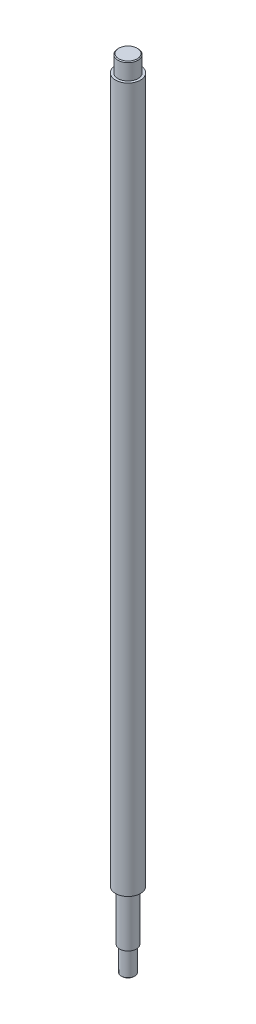
from build123d import *

# Parameters (mm, degrees)
SKETCH4_R           = 7.5
BOSS_EXTRUDE1_DEPTH = 421
SKETCH5_R           = 6
BOSS_EXTRUDE2_DEPTH = 10
CHAMFER1_SIZE       = 0.5
SKETCH6_R           = 5
BOSS_EXTRUDE3_DEPTH = 30
SKETCH7_R           = 4
BOSS_EXTRUDE4_DEPTH = 15
CHAMFER2_SIZE       = 0.5


with BuildPart() as part:
    # Sketch4 → Boss-Extrude1 (new body)
    with BuildSketch(Plane(origin=(0, 0, 0), x_dir=(1, 0, 0), z_dir=(0, 1, 0))):
        Circle(SKETCH4_R)
    extrude(amount=BOSS_EXTRUDE1_DEPTH)

    # Sketch5 → Boss-Extrude2 (add)
    with BuildSketch(Plane(origin=(0, 421, 0), x_dir=(1, 0, 0), z_dir=(0, 1, 0))):
        Circle(SKETCH5_R)
    extrude(amount=BOSS_EXTRUDE2_DEPTH)

    # Chamfer1
    chamfer1_edges = [part.edges().sort_by_distance(p)[0] for p in [
        (-6, 431, 0),
    ]]
    chamfer(chamfer1_edges, length=CHAMFER1_SIZE)

    # Sketch6 → Boss-Extrude3 (add)
    with BuildSketch(Plane.XZ):
        Circle(SKETCH6_R)
    extrude(amount=BOSS_EXTRUDE3_DEPTH)

    # Sketch7 → Boss-Extrude4 (add)
    with BuildSketch(Plane.XZ.offset(30)):
        Circle(SKETCH7_R)
    extrude(amount=BOSS_EXTRUDE4_DEPTH)

    # Chamfer2
    chamfer2_edges = [part.edges().sort_by_distance(p)[0] for p in [
        (-4, -45, 0),
    ]]
    chamfer(chamfer2_edges, length=CHAMFER2_SIZE)


solid = part.part
